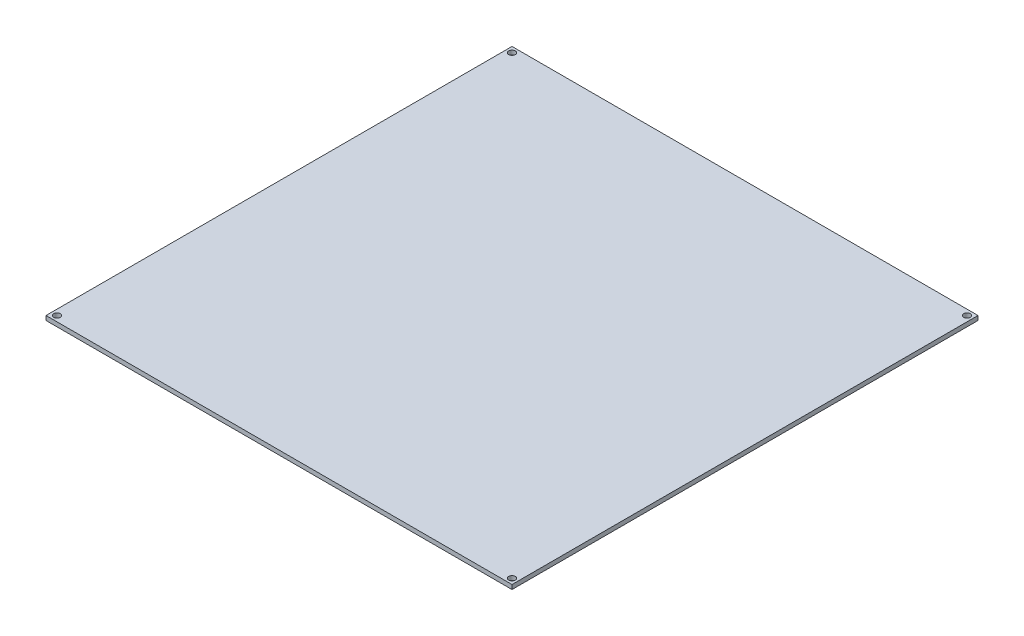
from build123d import *

# Parameters (mm, degrees)
SKETCH1_W           = 214
SKETCH1_H           = 214
SKETCH1_R           = 1.5
BOSS_EXTRUDE1_DEPTH = 2


with BuildPart() as part:
    # Sketch1 → Boss-Extrude1 (new body)
    with BuildSketch(Plane(origin=(0, 0, 0), x_dir=(1, 0, 0), z_dir=(0, 1, 0))):
        Rectangle(SKETCH1_W, SKETCH1_H)
        with Locations((-104.5, 104.5)):
            Circle(SKETCH1_R, mode=Mode.SUBTRACT)
        with Locations((104.5, 104.5)):
            Circle(SKETCH1_R, mode=Mode.SUBTRACT)
        with Locations((104.5, -104.5)):
            Circle(SKETCH1_R, mode=Mode.SUBTRACT)
        with Locations((-104.5, -104.5)):
            Circle(SKETCH1_R, mode=Mode.SUBTRACT)
    extrude(amount=BOSS_EXTRUDE1_DEPTH)


solid = part.part
